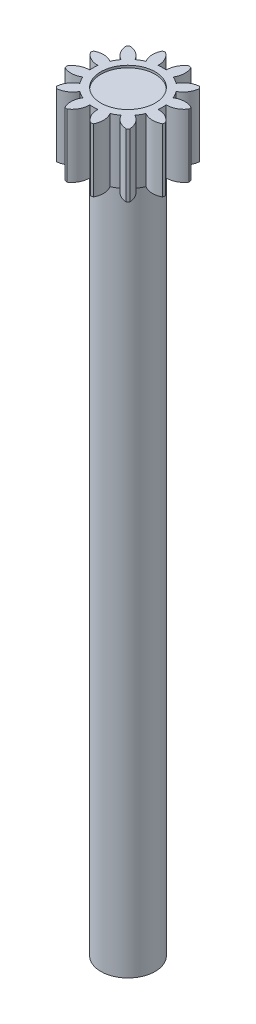
from build123d import *

# Parameters (mm, degrees)
BOSS_EXTRUDE1_DEPTH = 7
SKETCH2_R           = 3
CUT_EXTRUDE1_DEPTH  = 7
BOSS_EXTRUDE2_START = -0.25
SKETCH2_2_R         = 3
BOSS_EXTRUDE2_DEPTH = 82.81


with BuildPart() as part:
    # Sketch1 → Boss-Extrude1 (new body)
    with BuildSketch(Plane(origin=(0, 0, 0), x_dir=(1, 0, 0), z_dir=(0, 1, 0))):
        with BuildLine():
            ThreePointArc((-4.057364733, 3.859765721), (-3.757286187, 2.934610179), (-3.042339168, 2.275208427))
            ThreePointArc((-3.042339168, 2.275208427), (-3.290030509, 1.8995), (-3.491557881, 1.497138792))
            ThreePointArc((-3.491557881, 1.497138792), (-4.420090059, 1.786600197), (-5.371337534, 1.583898071))
            ThreePointArc((-5.371337534, 1.583898071), (-5.409184627, 1.449386653), (-5.443663792, 1.313972801))
            ThreePointArc((-5.443663792, 1.313972801), (-4.721210377, 0.662803872), (-3.77234722, 0.449218713))
            ThreePointArc((-3.77234722, 0.449218713), (-3.799, 0), (-3.77234722, -0.449218713))
            ThreePointArc((-3.77234722, -0.449218713), (-4.721210377, -0.662803872), (-5.443663792, -1.313972801))
            ThreePointArc((-5.443663792, -1.313972801), (-5.409184627, -1.449386653), (-5.371337534, -1.583898071))
            ThreePointArc((-5.371337534, -1.583898071), (-4.420090059, -1.786600197), (-3.491557881, -1.497138792))
            ThreePointArc((-3.491557881, -1.497138792), (-3.290030509, -1.8995), (-3.042339168, -2.275208427))
            ThreePointArc((-3.042339168, -2.275208427), (-3.757286187, -2.934610179), (-4.057364733, -3.859765721))
            ThreePointArc((-4.057364733, -3.859765721), (-3.959797975, -3.959797975), (-3.859765721, -4.057364733))
            ThreePointArc((-3.859765721, -4.057364733), (-2.934610179, -3.757286187), (-2.275208427, -3.042339168))
            ThreePointArc((-2.275208427, -3.042339168), (-1.8995, -3.290030509), (-1.497138792, -3.491557881))
            ThreePointArc((-1.497138792, -3.491557881), (-1.786600197, -4.420090059), (-1.583898071, -5.371337534))
            ThreePointArc((-1.583898071, -5.371337534), (-1.449386653, -5.409184627), (-1.313972801, -5.443663792))
            ThreePointArc((-1.313972801, -5.443663792), (-0.662803872, -4.721210377), (-0.449218713, -3.77234722))
            ThreePointArc((-0.449218713, -3.77234722), (0, -3.799), (0.449218713, -3.77234722))
            ThreePointArc((0.449218713, -3.77234722), (0.662803872, -4.721210377), (1.313972801, -5.443663792))
            ThreePointArc((1.313972801, -5.443663792), (1.449386653, -5.409184627), (1.583898071, -5.371337534))
            ThreePointArc((1.583898071, -5.371337534), (1.786600197, -4.420090059), (1.497138792, -3.491557881))
            ThreePointArc((1.497138792, -3.491557881), (1.8995, -3.290030509), (2.275208427, -3.042339168))
            ThreePointArc((2.275208427, -3.042339168), (2.934610179, -3.757286187), (3.859765721, -4.057364733))
            ThreePointArc((3.859765721, -4.057364733), (3.959797975, -3.959797975), (4.057364733, -3.859765721))
            ThreePointArc((4.057364733, -3.859765721), (3.757286187, -2.934610179), (3.042339168, -2.275208427))
            ThreePointArc((3.042339168, -2.275208427), (3.290030509, -1.8995), (3.491557881, -1.497138792))
            ThreePointArc((3.491557881, -1.497138792), (4.420090059, -1.786600197), (5.371337534, -1.583898071))
            ThreePointArc((5.371337534, -1.583898071), (5.409184627, -1.449386653), (5.443663792, -1.313972801))
            ThreePointArc((5.443663792, -1.313972801), (4.721210377, -0.662803872), (3.77234722, -0.449218713))
            ThreePointArc((3.77234722, -0.449218713), (3.799, 0), (3.77234722, 0.449218713))
            ThreePointArc((3.77234722, 0.449218713), (4.721210377, 0.662803872), (5.443663792, 1.313972801))
            ThreePointArc((5.443663792, 1.313972801), (5.409184627, 1.449386653), (5.371337534, 1.583898071))
            ThreePointArc((5.371337534, 1.583898071), (4.420090059, 1.786600197), (3.491557881, 1.497138792))
            ThreePointArc((3.491557881, 1.497138792), (3.290030509, 1.8995), (3.042339168, 2.275208427))
            ThreePointArc((3.042339168, 2.275208427), (3.757286187, 2.934610179), (4.057364733, 3.859765721))
            ThreePointArc((4.057364733, 3.859765721), (3.959797975, 3.959797975), (3.859765721, 4.057364733))
            ThreePointArc((3.859765721, 4.057364733), (2.934610179, 3.757286187), (2.275208427, 3.042339168))
            ThreePointArc((2.275208427, 3.042339168), (1.8995, 3.290030509), (1.497138792, 3.491557881))
            ThreePointArc((1.497138792, 3.491557881), (1.786600197, 4.420090059), (1.583898071, 5.371337534))
            ThreePointArc((1.583898071, 5.371337534), (1.449386653, 5.409184627), (1.313972801, 5.443663792))
            ThreePointArc((1.313972801, 5.443663792), (0.662803872, 4.721210377), (0.449218713, 3.77234722))
            ThreePointArc((0.449218713, 3.77234722), (0, 3.799), (-0.449218713, 3.77234722))
            ThreePointArc((-0.449218713, 3.77234722), (-0.662803872, 4.721210377), (-1.313972801, 5.443663792))
            ThreePointArc((-1.313972801, 5.443663792), (-1.449386653, 5.409184627), (-1.583898071, 5.371337534))
            ThreePointArc((-1.583898071, 5.371337534), (-1.786600197, 4.420090059), (-1.497138792, 3.491557881))
            ThreePointArc((-1.497138792, 3.491557881), (-1.8995, 3.290030509), (-2.275208427, 3.042339168))
            ThreePointArc((-2.275208427, 3.042339168), (-2.934610179, 3.757286187), (-3.859765721, 4.057364733))
            ThreePointArc((-3.859765721, 4.057364733), (-3.959797975, 3.959797975), (-4.057364733, 3.859765721))
        make_face()
    extrude(amount=BOSS_EXTRUDE1_DEPTH)

    # Sketch2 → Cut-Extrude1 (cut)
    with BuildSketch(Plane(origin=(0, 7, 0), x_dir=(1, 0, 0), z_dir=(0, 1, 0))):
        Circle(SKETCH2_R)
    extrude(amount=-CUT_EXTRUDE1_DEPTH, mode=Mode.SUBTRACT)

    # Sketch2_2 → Boss-Extrude2 (add)
    with BuildSketch(Plane(origin=(0, 7, 0), x_dir=(1, 0, 0), z_dir=(0, 1, 0)).offset(BOSS_EXTRUDE2_START)):
        Circle(SKETCH2_2_R)
    extrude(amount=-BOSS_EXTRUDE2_DEPTH)


solid = part.part
